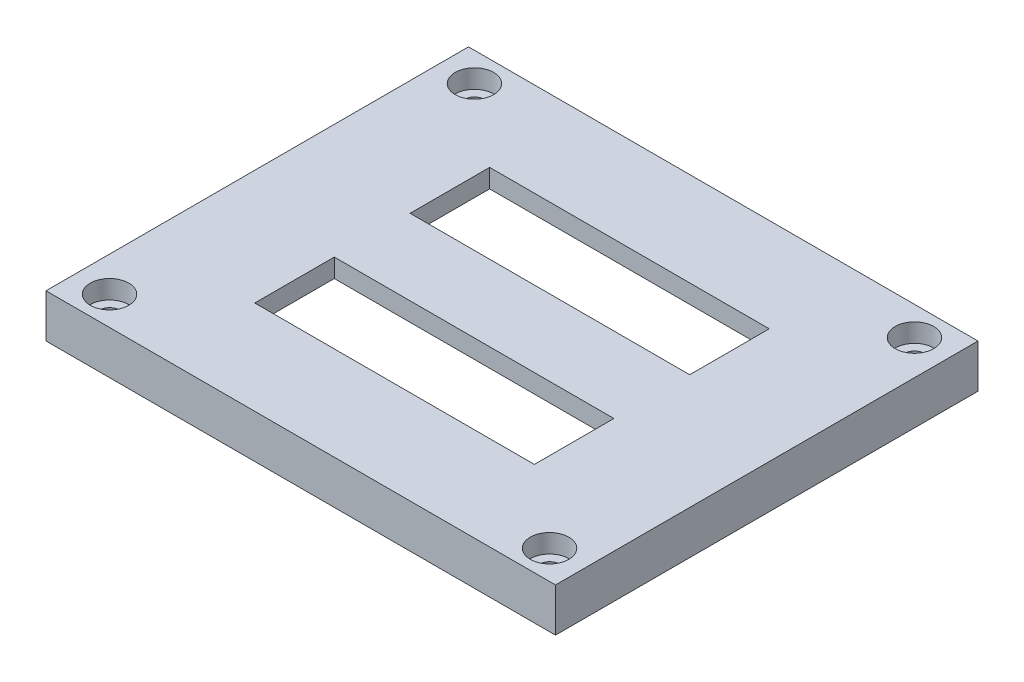
from build123d import *

# Parameters (mm, degrees)
SKETCH1_W             = 76
SKETCH1_H             = 62
BOSS_EXTRUDE1_DEPTH   = 2
SKETCH2_W             = 82
SKETCH2_H             = 68
BOSS_EXTRUDE2_DEPTH   = 8
SKETCH3_W             = 45
SKETCH3_H             = 12.8
CUT_EXTRUDE1_DEPTH    = 11
SKETCH4_R             = 1.6
CUT_EXTRUDE2_DEPTH    = 11
SKETCH5_R             = 3.1
CUT_EXTRUDE3_DEPTH    = 3
SKETCH9_OUTSIDE_W     = 105.4
SKETCH9_OUTSIDE_H     = 91.4
SKETCH9_OUTSIDE_W_2   = 75.6
SKETCH9_OUTSIDE_H_2   = 61.6
CUT_EXTRUDE5_DEPTH    = 3
CUT_EXTRUDE6_DEPTH    = 3
SKETCH11_W            = 66
SKETCH11_H            = 54
CUT_EXTRUDE7_DEPTH    = 7
CHAMFER2_SIZE         = 2
CHAMFER2_SIZE2        = 0.352653961
CHAMFER2_PART_2_SIZE  = 2
CHAMFER2_PART_2_SIZE2 = 0.352653961
CHAMFER3_SIZE         = 1
CHAMFER3_SIZE2        = 1.732050808


with BuildPart() as part:
    # Sketch1 → Boss-Extrude1 (new body)
    with BuildSketch(Plane(origin=(0, 0, 0), x_dir=(1, 0, 0), z_dir=(0, 1, 0))):
        Rectangle(SKETCH1_W, SKETCH1_H)
    extrude(amount=BOSS_EXTRUDE1_DEPTH)

    # Sketch2 → Boss-Extrude2 (add)
    with BuildSketch(Plane(origin=(0, 2, 0), x_dir=(1, 0, 0), z_dir=(0, 1, 0))):
        Rectangle(SKETCH2_W, SKETCH2_H)
    extrude(amount=BOSS_EXTRUDE2_DEPTH)

    # Sketch3 → Cut-Extrude1 (cut, through all)
    with BuildSketch(Plane.XZ):
        with Locations((0, -12.5)):
            Rectangle(SKETCH3_W, SKETCH3_H)
        with Locations((0, 12.5)):
            Rectangle(SKETCH3_W, SKETCH3_H)
    extrude(amount=-CUT_EXTRUDE1_DEPTH, mode=Mode.SUBTRACT)

    # Sketch4 → Cut-Extrude2 (cut, through all)
    with BuildSketch(Plane(origin=(0, 10, 0), x_dir=(1, 0, 0), z_dir=(0, 1, 0))):
        with Locations(Location((-35.408866178, 29.363450001, 0), (0, 0, 270))):  # turned: the seam where the file's is
            Circle(SKETCH4_R)
        with Locations(Location((35.408866178, 29.363450001, 0), (0, 0, 270))):  # turned: the seam where the file's is
            Circle(SKETCH4_R)
        with Locations(Location((35.408866178, -29.363450001, 0), (0, 0, 270))):  # turned: the seam where the file's is
            Circle(SKETCH4_R)
        with Locations(Location((-35.408866178, -29.363450001, 0), (0, 0, 270))):  # turned: the seam where the file's is
            Circle(SKETCH4_R)
    extrude(amount=-CUT_EXTRUDE2_DEPTH, mode=Mode.SUBTRACT)

    # Sketch5 → Cut-Extrude3 (cut)
    with BuildSketch(Plane(origin=(0, 10, 0), x_dir=(1, 0, 0), z_dir=(0, 1, 0))):
        with Locations(Location((-35.408866178, 29.363450001, 0), (0, 0, 270))):  # turned: the seam where the file's is
            Circle(SKETCH5_R)
        with Locations(Location((35.408866178, 29.363450001, 0), (0, 0, 270))):  # turned: the seam where the file's is
            Circle(SKETCH5_R)
        with Locations(Location((35.408866178, -29.363450001, 0), (0, 0, 270))):  # turned: the seam where the file's is
            Circle(SKETCH5_R)
        with Locations(Location((-35.408866178, -29.363450001, 0), (0, 0, 270))):  # turned: the seam where the file's is
            Circle(SKETCH5_R)
    extrude(amount=-CUT_EXTRUDE3_DEPTH, mode=Mode.SUBTRACT)

    # Sketch9 outside → Cut-Extrude5 (cut)
    with BuildSketch(Plane.XZ):
        Rectangle(SKETCH9_OUTSIDE_W, SKETCH9_OUTSIDE_H)
        Rectangle(SKETCH9_OUTSIDE_W_2, SKETCH9_OUTSIDE_H_2, mode=Mode.SUBTRACT)
    extrude(amount=-CUT_EXTRUDE5_DEPTH, mode=Mode.SUBTRACT)

    # Sketch10 → Cut-Extrude6 (cut)
    with BuildSketch(Plane.XZ):
        Polygon((-37.8, -30.8), (-31.8, -30.8), (-37.8, -24.8), align=None)
        Polygon((-37.8, 24.8), (-37.8, 30.8), (-31.8, 30.8), align=None)
        Polygon((37.8, 30.8), (37.8, 24.8), (31.8, 30.8), align=None)
        Polygon((37.8, -30.8), (31.8, -30.8), (37.8, -24.8), align=None)
    extrude(amount=-CUT_EXTRUDE6_DEPTH, mode=Mode.SUBTRACT)

    # Sketch11 → Cut-Extrude7 (cut)
    with BuildSketch(Plane.XZ):
        Rectangle(SKETCH11_W, SKETCH11_H)
    extrude(amount=-CUT_EXTRUDE7_DEPTH, mode=Mode.SUBTRACT)

    # Chamfer2
    chamfer2_edges = [part.edges().sort_by_distance(p)[0] for p in [
        (37.8, 0, 0),
    ]]
    chamfer2_side = [part.faces().sort_by_distance(p)[0] for p in [
        (37.8, 1.5, 0),
    ]]
    chamfer(chamfer2_edges, length=CHAMFER2_SIZE, length2=CHAMFER2_SIZE2, reference=chamfer2_side[0])

    # Chamfer2 part 2
    chamfer2_part_2_edges = [part.edges().sort_by_distance(p)[0] for p in [
        (-37.8, 0, 0),
    ]]
    chamfer2_part_2_side = [part.faces().sort_by_distance(p)[0] for p in [
        (-37.8, 1.5, 0),
    ]]
    chamfer(chamfer2_part_2_edges, length=CHAMFER2_PART_2_SIZE, length2=CHAMFER2_PART_2_SIZE2, reference=chamfer2_part_2_side[0])

    # Chamfer3
    chamfer3_edges = [part.edges().sort_by_distance(p)[0] for p in [
        (0, 0, -30.8),
        (0, 0, 30.8),
    ]]
    chamfer3_side = [part.faces().sort_by_distance(p)[0] for p in [
        (-35.357643735, 0, 25.870950059),
    ]]
    chamfer(chamfer3_edges, length=CHAMFER3_SIZE, length2=CHAMFER3_SIZE2, reference=chamfer3_side[0])


solid = part.part
